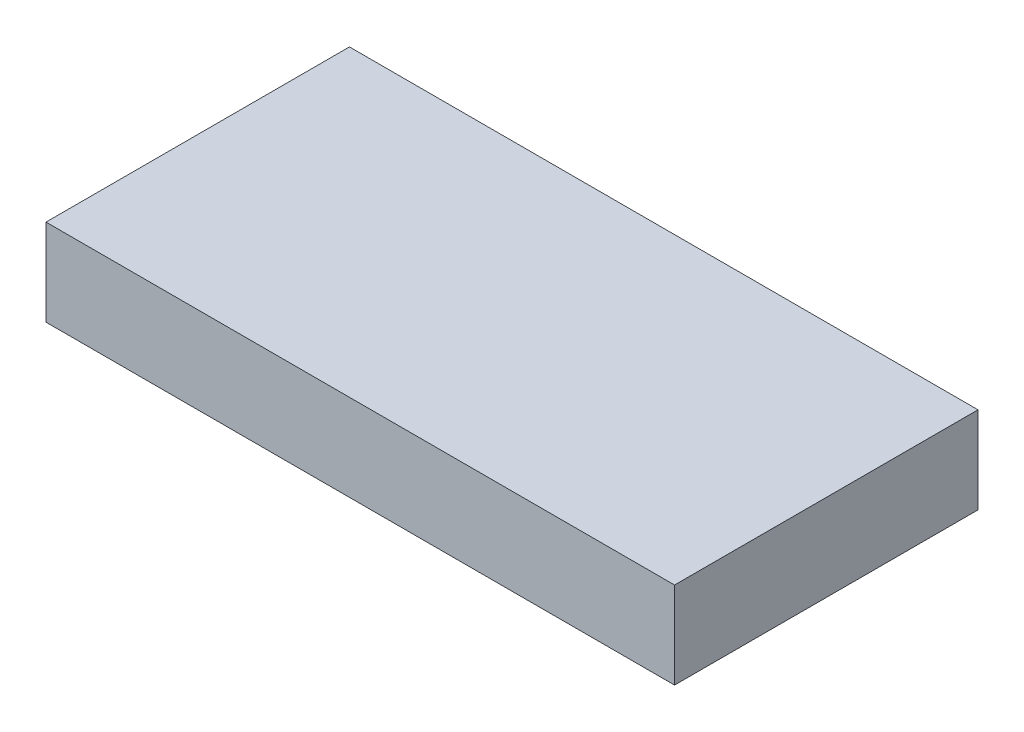
from build123d import *

# Parameters (mm, degrees)
SKETCH1_W           = 29
SKETCH1_H           = 14
BOSS_EXTRUDE1_DEPTH = 2


with BuildPart() as part:
    # Sketch1 → Boss-Extrude1 (new body, symmetric)
    with BuildSketch(Plane(origin=(0, 0, 0), x_dir=(1, 0, 0), z_dir=(0, 1, 0))):
        Rectangle(SKETCH1_W, SKETCH1_H)
    extrude(amount=BOSS_EXTRUDE1_DEPTH, both=True)


solid = part.part
